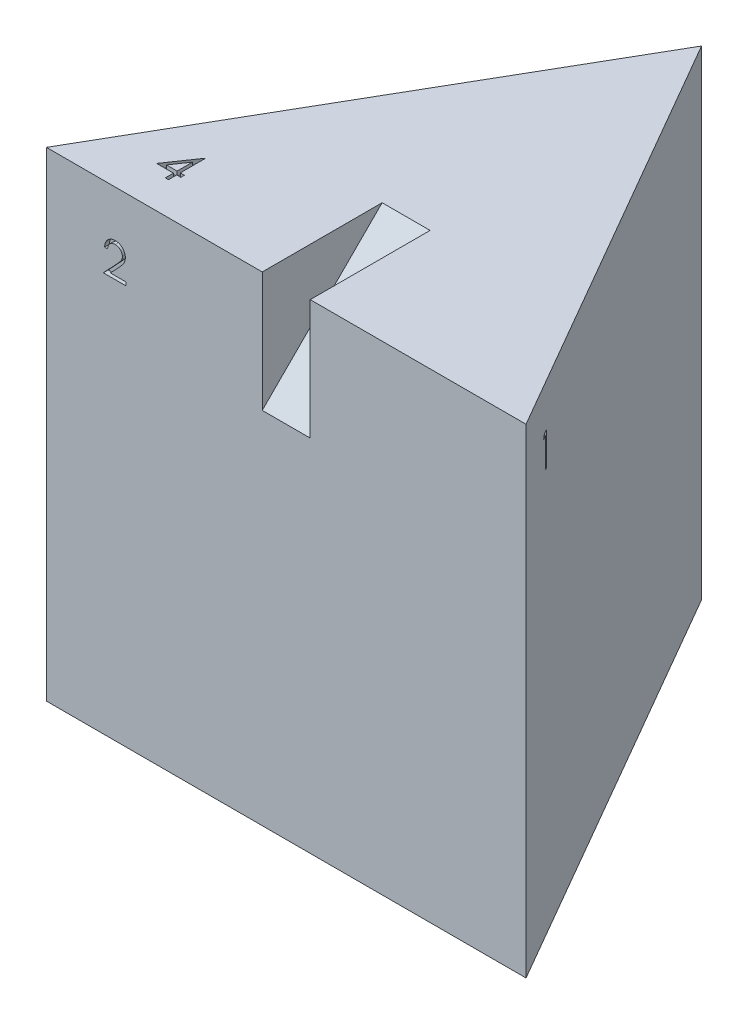
from build123d import *

# Parameters (mm, degrees)
BOSS_EXTRUDE1_DEPTH = 100
CUT_EXTRUDE1_DEPTH  = 5
CUT_EXTRUDE2_DEPTH  = 1
CUT_EXTRUDE3_DEPTH  = 1
CUT_EXTRUDE4_DEPTH  = 1
CUT_EXTRUDE5_DEPTH  = 1


with BuildPart() as part:
    # Sketch1 → Boss-Extrude1 (new body)
    with BuildSketch(Plane(origin=(0, 0, 0), x_dir=(1, 0, 0), z_dir=(0, 1, 0))):
        Polygon((0, 0), (-50, -86.602540378), (50, -86.602540378), align=None)
    extrude(amount=BOSS_EXTRUDE1_DEPTH)

    # Sketch2 → Cut-Extrude1 (cut, symmetric)
    with BuildSketch(Plane(origin=(0, 0, 0), x_dir=(0, 0, -1), z_dir=(1, 0, 0))):
        Polygon((-86.602540378, 100), (-61.602540378, 100), (-86.602540378, 75), align=None)
    extrude(amount=CUT_EXTRUDE1_DEPTH, both=True, mode=Mode.SUBTRACT)

    # Sketch3 → Cut-Extrude2 (cut)
    with BuildSketch(Plane(origin=(0, 0, 0), x_dir=(-0.5, 0, -0.866025404), z_dir=(0.866025404, 0, -0.5))):
        Polygon((-89.562682325, 91.072269243), (-88.290753072, 91.072269243), (-88.290753072, 84.193102577), (-88.908114183, 84.193102577), (-88.908114183, 90.366713688), (-89.966447516, 90.366713688), align=None)
    extrude(amount=-CUT_EXTRUDE2_DEPTH, mode=Mode.SUBTRACT)

    # Sketch4 → Cut-Extrude3 (cut)
    with BuildSketch(Plane.XY.offset(86.602540378)):
        with BuildLine():
            Line((-37.25444002, 88.042823018), (-37.871801131, 88.042823018))
            add(Edge.make_bspline(
                [(-37.871801131, 88.042823018), (-37.8677775, 88.124726156), (-37.859875197, 88.285581739), (-37.822868643, 88.520110036), (-37.76991699, 88.744282027), (-37.695049144, 88.956297775), (-37.602069782, 89.158031906), (-37.490568264, 89.348683128), (-37.35850035, 89.527524143), (-37.208717829, 89.692897036), (-37.04603804, 89.844607368), (-36.870509342, 89.975616661), (-36.686059175, 90.086307703), (-36.493247142, 90.178844763), (-36.289897868, 90.248304389), (-36.077856679, 90.299842397), (-35.856191972, 90.330850429), (-35.705164738, 90.334183455), (-35.62835495, 90.335878574)],
                knots=[0, 0, 0, 0, 0.000245848, 0.000482838, 0.000711119, 0.000936005, 0.001156121, 0.001376628, 0.001597398, 0.00182182, 0.002045134, 0.002263691, 0.002477572, 0.002689615, 0.002904032, 0.003120949, 0.00334351, 0.003573844, 0.003573844, 0.003573844, 0.003573844], degree=3))
            add(Edge.make_bspline(
                [(-35.62835495, 90.335878574), (-35.55292376, 90.334112679), (-35.404704164, 90.330642759), (-35.188379895, 90.300844117), (-34.982442618, 90.254172722), (-34.787294877, 90.188692064), (-34.604493671, 90.100669339), (-34.432665758, 89.994931557), (-34.269765498, 89.87263996), (-34.123127641, 89.728661334), (-33.988476643, 89.574956409), (-33.872312567, 89.410862922), (-33.7728336, 89.241381314), (-33.689914719, 89.065219218), (-33.628874618, 88.880717947), (-33.582532211, 88.690563623), (-33.556337497, 88.492787953), (-33.552317266, 88.35892614), (-33.550273353, 88.290869893)],
                knots=[0, 0, 0, 0, 0.000226204, 0.000444483, 0.000653745, 0.000858999, 0.001060555, 0.001260974, 0.00146355, 0.001670164, 0.001876285, 0.002075887, 0.00227229, 0.002465264, 0.00265875, 0.002854281, 0.003051706, 0.003255884, 0.003255884, 0.003255884, 0.003255884], degree=3))
            add(Edge.make_bspline(
                [(-33.550273353, 88.290869893), (-33.553601421, 88.195057185), (-33.560199154, 88.005113146), (-33.616636577, 87.725986315), (-33.704781327, 87.455549725), (-33.810911846, 87.237898195), (-33.917976138, 87.062511887), (-34.014456466, 86.918110897), (-34.127402183, 86.762630982), (-34.258457184, 86.596592787), (-34.40491046, 86.418695758), (-34.568088545, 86.229047363), (-34.749155056, 86.029607015), (-34.876239799, 85.893388506), (-34.94209193, 85.822803487)],
                knots=[0, 0, 0, 0, 0.000287191, 0.000569343, 0.000850854, 0.001138679, 0.001293241, 0.001467141, 0.001659539, 0.001869599, 0.002101621, 0.002350787, 0.002620073, 0.002909674, 0.002909674, 0.002909674, 0.002909674], degree=3))
            Line((-34.94209193, 85.822803487), (-36.663261634, 83.985878574))
            Line((-36.663261634, 83.985878574), (-33.462078909, 83.985878574))
            Line((-33.462078909, 83.985878574), (-33.462078909, 83.280323018))
            Line((-33.462078909, 83.280323018), (-38.136384464, 83.280323018))
            Line((-38.136384464, 83.280323018), (-35.46850252, 86.127349928))
            add(Edge.make_bspline(
                [(-35.46850252, 86.127349928), (-35.403547685, 86.195155528), (-35.278782741, 86.325396209), (-35.102317224, 86.515542194), (-34.943823213, 86.691942779), (-34.802274742, 86.854264674), (-34.680742459, 87.004882196), (-34.572892394, 87.138917262), (-34.486479072, 87.26225964), (-34.392695597, 87.405229585), (-34.301863117, 87.57978808), (-34.223809427, 87.793108462), (-34.176215719, 88.012705717), (-34.170506334, 88.161103173), (-34.167634464, 88.235748365)],
                knots=[0, 0, 0, 0, 0.00028169, 0.000541069, 0.000778192, 0.00099313, 0.001187047, 0.001358794, 0.001509057, 0.001638637, 0.001871619, 0.002097432, 0.002318512, 0.002542268, 0.002542268, 0.002542268, 0.002542268], degree=3))
            add(Edge.make_bspline(
                [(-34.167634464, 88.235748365), (-34.168884001, 88.282686685), (-34.171346597, 88.375193101), (-34.193080238, 88.510822277), (-34.22592434, 88.641653834), (-34.272988174, 88.768090203), (-34.33511047, 88.888860169), (-34.410728982, 89.00411074), (-34.497976594, 89.115531552), (-34.598906292, 89.220003093), (-34.709781791, 89.315684844), (-34.826912869, 89.400444207), (-34.950836348, 89.471278221), (-35.081029731, 89.529345261), (-35.217130053, 89.574895921), (-35.359400546, 89.606458677), (-35.507448106, 89.626275559), (-35.608539417, 89.628956806), (-35.660049829, 89.630323018)],
                knots=[0, 0, 0, 0, 0.000140729, 0.000277349, 0.00041104, 0.000544909, 0.000681112, 0.000817565, 0.000957888, 0.001105055, 0.001252582, 0.001396757, 0.001538112, 0.001679989, 0.001823795, 0.001967884, 0.002116591, 0.002271085, 0.002271085, 0.002271085, 0.002271085], degree=3))
            add(Edge.make_bspline(
                [(-35.660049829, 89.630323018), (-35.713846549, 89.628917639), (-35.819494425, 89.626157707), (-35.974607905, 89.606851495), (-36.122580308, 89.573544849), (-36.263783858, 89.527991647), (-36.398457472, 89.470091571), (-36.525946206, 89.397974821), (-36.645963861, 89.311919407), (-36.758736052, 89.214352076), (-36.862638944, 89.105724921), (-36.953929173, 88.984632006), (-37.033696086, 88.853284312), (-37.103292092, 88.712036249), (-37.159810716, 88.559606141), (-37.20299842, 88.396535093), (-37.237171853, 88.223531163), (-37.248588362, 88.104059526), (-37.25444002, 88.042823018)],
                knots=[0, 0, 0, 0, 0.000161378, 0.000316919, 0.000468033, 0.000615766, 0.000761428, 0.000907057, 0.001054275, 0.001203746, 0.001353858, 0.001504342, 0.001657725, 0.001814265, 0.001976036, 0.002144518, 0.002319919, 0.00250436, 0.00250436, 0.00250436, 0.00250436], degree=3))
        make_face()
    extrude(amount=-CUT_EXTRUDE3_DEPTH, mode=Mode.SUBTRACT)

    # Sketch5 → Cut-Extrude4 (cut)
    with BuildSketch(Plane(origin=(0, 0, 0), x_dir=(-0.5, 0, 0.866025404), z_dir=(-0.866025404, 0, -0.5))):
        with BuildLine():
            Line((9.368861723, 90.468822877), (8.751500612, 90.468822877))
            add(Edge.make_bspline(
                [(8.751500612, 90.468822877), (8.768225931, 90.538071486), (8.800922562, 90.673446851), (8.869119817, 90.866863979), (8.943413353, 91.049896043), (9.032624557, 91.219115826), (9.129932835, 91.377924146), (9.241419994, 91.522719056), (9.361942448, 91.657183111), (9.495250771, 91.776513533), (9.635052462, 91.884570951), (9.783317411, 91.97670276), (9.937062646, 92.055958923), (10.097353387, 92.121252497), (10.264666851, 92.170439568), (10.437490432, 92.206126337), (10.616277026, 92.229301492), (10.737640445, 92.231563289), (10.799265369, 92.232711766)],
                knots=[0, 0, 0, 0, 0.000213578, 0.000417528, 0.000614587, 0.000805658, 0.000990731, 0.001172638, 0.001353118, 0.001531653, 0.001708601, 0.001882572, 0.002054524, 0.002226999, 0.002400965, 0.002576906, 0.002756035, 0.002940821, 0.002940821, 0.002940821, 0.002940821], degree=3))
            add(Edge.make_bspline(
                [(10.799265369, 92.232711766), (10.889053711, 92.230000922), (11.06667185, 92.224638365), (11.327614458, 92.175669633), (11.579248123, 92.098180474), (11.818818537, 91.991113661), (12.041346671, 91.859058596), (12.239341247, 91.70188981), (12.410118547, 91.522639754), (12.55339071, 91.324652297), (12.665570262, 91.113057957), (12.748290027, 90.895282886), (12.798648831, 90.671843678), (12.805175306, 90.520979073), (12.808445057, 90.445396228)],
                knots=[0, 0, 0, 0, 0.000269145, 0.000532418, 0.000793509, 0.001057535, 0.001317736, 0.001567815, 0.001813439, 0.002058218, 0.002298645, 0.00252977, 0.002755469, 0.002982072, 0.002982072, 0.002982072, 0.002982072], degree=3))
            add(Edge.make_bspline(
                [(12.808445057, 90.445396228), (12.806158046, 90.372660254), (12.801682721, 90.23032724), (12.763682783, 90.022534155), (12.699733533, 89.826690962), (12.611149988, 89.641973226), (12.49648106, 89.469552142), (12.357575557, 89.309039778), (12.193453064, 89.159724206), (12.069079818, 89.074187718), (12.005048789, 89.030151002)],
                knots=[0, 0, 0, 0, 0.000218083, 0.000426755, 0.000631137, 0.000834532, 0.001039392, 0.001250443, 0.001469949, 0.001702875, 0.001702875, 0.001702875, 0.001702875], degree=3))
            add(Edge.make_bspline(
                [(12.005048789, 89.030151002), (12.078226916, 88.994815334), (12.223213951, 88.924805156), (12.420843623, 88.787505327), (12.600248114, 88.628977197), (12.700298162, 88.505264911), (12.750567452, 88.443106731)],
                knots=[0, 0, 0, 0, 0.000243449, 0.000482343, 0.000719466, 0.000958915, 0.000958915, 0.000958915, 0.000958915], degree=3))
            add(Edge.make_bspline(
                [(12.750567452, 88.443106731), (12.78366871, 88.39778727), (12.849329169, 88.307890484), (12.930376628, 88.163356389), (13.003903352, 88.017220307), (13.061197414, 87.865565332), (13.105565812, 87.710149206), (13.137280799, 87.550705068), (13.156983009, 87.387102717), (13.159804552, 87.276421878), (13.161222834, 87.220786853)],
                knots=[0, 0, 0, 0, 0.000168211, 0.000333667, 0.000496369, 0.000658627, 0.000819143, 0.000980756, 0.001145874, 0.001312759, 0.001312759, 0.001312759, 0.001312759], degree=3))
            add(Edge.make_bspline(
                [(13.161222834, 87.220786853), (13.157695761, 87.124459413), (13.150658212, 86.932257851), (13.087754966, 86.648296226), (12.990241323, 86.370720863), (12.851759893, 86.105234483), (12.682989348, 85.856836853), (12.48220156, 85.63458806), (12.251677917, 85.443546517), (11.994582528, 85.283929748), (11.716040887, 85.156335117), (11.418122669, 85.067775786), (11.10512048, 85.010096923), (10.890476137, 85.003911827), (10.781350872, 85.000767322)],
                knots=[0, 0, 0, 0, 0.000288655, 0.000575952, 0.000868412, 0.001169178, 0.001471521, 0.001767132, 0.00206461, 0.002366686, 0.002672561, 0.002980765, 0.003297042, 0.003624128, 0.003624128, 0.003624128, 0.003624128], degree=3))
            add(Edge.make_bspline(
                [(10.781350872, 85.000767322), (10.707804129, 85.002473774), (10.563088662, 85.005831504), (10.350338643, 85.028785516), (10.147262303, 85.070709134), (9.95358507, 85.127124797), (9.769134885, 85.1986519), (9.594474602, 85.287724721), (9.428529657, 85.392507209), (9.272866004, 85.514236202), (9.1275022, 85.650407025), (8.99630131, 85.803437056), (8.877075931, 85.970497429), (8.773018435, 86.153528579), (8.679389139, 86.35016515), (8.602379902, 86.562924997), (8.534599338, 86.789906092), (8.503085945, 86.948083174), (8.486917279, 87.029239544)],
                knots=[0, 0, 0, 0, 0.000220641, 0.000434148, 0.000640895, 0.000841923, 0.001038713, 0.00123346, 0.0014292, 0.001626568, 0.001825435, 0.002025726, 0.002230293, 0.00244019, 0.00265656, 0.002882848, 0.003118327, 0.00336645, 0.00336645, 0.00336645, 0.00336645], degree=3))
            Line((8.486917279, 87.029239544), (9.10427839, 87.029239544))
            add(Edge.make_bspline(
                [(9.10427839, 87.029239544), (9.120362454, 86.9762719), (9.151647357, 86.873245232), (9.204900555, 86.724969107), (9.265571408, 86.5890406), (9.330657285, 86.464462583), (9.399013492, 86.350008182), (9.475499851, 86.248703866), (9.55445135, 86.156100058), (9.613964698, 86.103927255), (9.643091324, 86.07839319)],
                knots=[0, 0, 0, 0, 0.000166058, 0.000322997, 0.00047229, 0.000612207, 0.000744556, 0.000871612, 0.000992692, 0.00110875, 0.00110875, 0.00110875, 0.00110875], degree=3))
            add(Edge.make_bspline(
                [(9.643091324, 86.07839319), (9.681607928, 86.048698119), (9.758522246, 85.98939964), (9.883857186, 85.913725606), (10.015671622, 85.848155305), (10.156821655, 85.798067708), (10.3042614, 85.755657329), (10.460373995, 85.727903785), (10.623782147, 85.708861915), (10.735357834, 85.707181567), (10.792375178, 85.706322877)],
                knots=[0, 0, 0, 0, 0.000145799, 0.000291148, 0.000438443, 0.00058667, 0.000739806, 0.000898191, 0.001061783, 0.001232749, 0.001232749, 0.001232749, 0.001232749], degree=3))
            add(Edge.make_bspline(
                [(10.792375178, 85.706322877), (10.856751408, 85.707533424), (10.982633567, 85.709900545), (11.166316868, 85.731669583), (11.34106234, 85.763373526), (11.50492984, 85.812339401), (11.660065873, 85.872838432), (11.804295758, 85.948800952), (11.939512867, 86.037924923), (12.063985305, 86.139223912), (12.175910344, 86.250119017), (12.274458364, 86.366107804), (12.358236121, 86.486701226), (12.425816226, 86.612566628), (12.479179986, 86.743182798), (12.515508276, 86.878916283), (12.540767623, 87.018656266), (12.542824715, 87.113645704), (12.543861723, 87.161531211)],
                knots=[0, 0, 0, 0, 0.000193048, 0.000377489, 0.000554244, 0.000725176, 0.000889718, 0.00105306, 0.001213203, 0.001374834, 0.001533667, 0.001685233, 0.001830869, 0.001973294, 0.002113014, 0.002253093, 0.002394233, 0.002537714, 0.002537714, 0.002537714, 0.002537714], degree=3))
            add(Edge.make_bspline(
                [(12.543861723, 87.161531211), (12.540853952, 87.225628021), (12.534853376, 87.353502704), (12.489040918, 87.541633317), (12.413686793, 87.722896239), (12.30819475, 87.894198869), (12.179778931, 88.05296198), (12.029685525, 88.194616763), (11.856668138, 88.311503811), (11.697425514, 88.392262587), (11.556372808, 88.447368791), (11.435662332, 88.484073989), (11.300522865, 88.515155352), (11.152588648, 88.544071972), (10.990745017, 88.568682383), (10.815168168, 88.589205524), (10.625822522, 88.605627158), (10.494742624, 88.612960537), (10.427195057, 88.616739544)],
                knots=[0, 0, 0, 0, 0.000192146, 0.000383336, 0.000577322, 0.000778916, 0.000984664, 0.001188432, 0.001395601, 0.001608837, 0.001722715, 0.001849562, 0.001986938, 0.002138553, 0.002301681, 0.002477908, 0.002668795, 0.002871746, 0.002871746, 0.002871746, 0.002871746], degree=3))
            Line((10.427195057, 88.616739544), (10.427195057, 89.322295099))
            add(Edge.make_bspline(
                [(10.427195057, 89.322295099), (10.512302467, 89.323739339), (10.679006976, 89.326568249), (10.922518283, 89.360783279), (11.155374757, 89.40811318), (11.372415889, 89.480610147), (11.570238539, 89.56481173), (11.741863138, 89.662795061), (11.884885233, 89.771711431), (11.998609791, 89.893241953), (12.084165454, 90.0235826), (12.146720266, 90.159429745), (12.18367186, 90.30197406), (12.188604551, 90.399254651), (12.191083945, 90.448152304)],
                knots=[0, 0, 0, 0, 0.000255119, 0.000499716, 0.000736482, 0.000967011, 0.001184871, 0.001380582, 0.00155837, 0.001722177, 0.001877352, 0.002024131, 0.002169185, 0.002315783, 0.002315783, 0.002315783, 0.002315783], degree=3))
            add(Edge.make_bspline(
                [(12.191083945, 90.448152304), (12.190269431, 90.484076777), (12.188648992, 90.555546812), (12.16821339, 90.65996287), (12.137504709, 90.761186753), (12.095286813, 90.858787997), (12.038778982, 90.95208969), (11.971154834, 91.041887283), (11.890633009, 91.127668091), (11.79836285, 91.207624291), (11.699279648, 91.283824303), (11.590687531, 91.348515273), (11.475860727, 91.403833723), (11.354672109, 91.449451446), (11.226728394, 91.483767262), (11.092630719, 91.508406159), (10.952123379, 91.523810883), (10.856263701, 91.526028758), (10.807533598, 91.527156211)],
                knots=[0, 0, 0, 0, 0.000107628, 0.000214121, 0.000317868, 0.000424629, 0.00053216, 0.000644332, 0.000761328, 0.000884352, 0.001010305, 0.001135797, 0.001262764, 0.001392277, 0.001523654, 0.001659606, 0.001800981, 0.001947157, 0.001947157, 0.001947157, 0.001947157], degree=3))
            add(Edge.make_bspline(
                [(10.807533598, 91.527156211), (10.729206094, 91.524421522), (10.57621426, 91.519080038), (10.355658512, 91.472295782), (10.150621345, 91.397650763), (9.993896894, 91.308549793), (9.878164597, 91.220593881), (9.795463377, 91.143778381), (9.714248897, 91.0584122), (9.63986412, 90.959237465), (9.564637531, 90.852970476), (9.496151374, 90.734209169), (9.429600956, 90.606051484), (9.38950023, 90.515451612), (9.368861723, 90.468822877)],
                knots=[0, 0, 0, 0, 0.000234756, 0.000458534, 0.000673048, 0.000887217, 0.00099636, 0.001108525, 0.00122552, 0.001349283, 0.001480015, 0.001615911, 0.001760131, 0.001913069, 0.001913069, 0.001913069, 0.001913069], degree=3))
        make_face()
    extrude(amount=-CUT_EXTRUDE4_DEPTH, mode=Mode.SUBTRACT)

    # Sketch6 → Cut-Extrude5 (cut)
    with BuildSketch(Plane(origin=(0, 100, 0), x_dir=(1, 0, 0), z_dir=(0, 1, 0))):
        Polygon((-31.569179002, -72.129020208), (-31.434131259, -72.129020208), (-31.434131259, -77.257866362), (-30.579323566, -77.257866362), (-30.579323566, -78.017695422), (-31.434131259, -78.017695422), (-31.434131259, -79.727310807), (-32.098981686, -79.727310807), (-32.098981686, -78.017695422), (-35.613191088, -78.017695422), align=None)
        Polygon((-32.098981686, -77.257866362), (-32.098981686, -74.040465187), (-34.307234891, -77.257866362), align=None, mode=Mode.SUBTRACT)
    extrude(amount=-CUT_EXTRUDE5_DEPTH, mode=Mode.SUBTRACT)


solid = part.part
